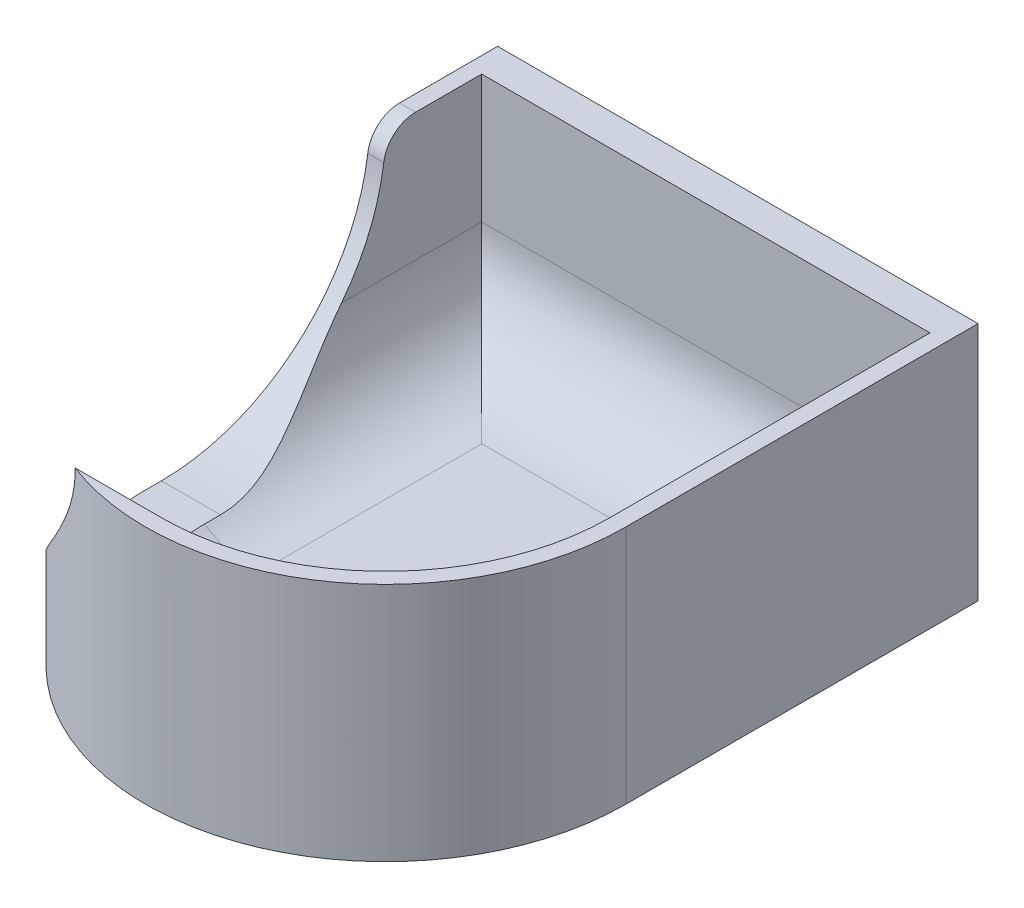
from build123d import *

# Parameters (mm, degrees)
BOSS_EXTRUDE1_DEPTH = 1.27
BOSS_EXTRUDE3_DEPTH = 17.78
SKETCH5_W           = 38.1
SKETCH5_H           = 19.05
BOSS_EXTRUDE4_DEPTH = 2.54
FILLET1_R           = 7.62
CUT_EXTRUDE5_REACH  = 40.1
FILLET3_R           = 2.54


with BuildPart() as part:
    # Sketch1 → Boss-Extrude1 (new body)
    with BuildSketch(Plane(origin=(0, 0, 0), x_dir=(1, 0, 0), z_dir=(0, 1, 0))):
        with BuildLine():
            Line((0, 0), (38.1, 0))
            Line((38.1, 0), (38.1, -25.4))
            ThreePointArc((38.1, -25.4), (19.05, -44.45), (0, -25.4))
            Line((0, -25.4), (0, 0))
        make_face()
    extrude(amount=BOSS_EXTRUDE1_DEPTH)

    # Sketch3 → Boss-Extrude3 (add)
    with BuildSketch(Plane(origin=(0, 1.27, 0), x_dir=(1, 0, 0), z_dir=(0, 1, 0))):
        with BuildLine():
            Line((0, 0), (0, -25.4))
            ThreePointArc((0, -25.4), (19.05, -44.45), (38.1, -25.4))
            Line((38.1, -25.4), (38.1, 0))
            Line((38.1, 0), (36.83, 0))
            Line((36.83, 0), (36.83, -25.4))
            ThreePointArc((36.83, -25.4), (19.05, -43.18), (1.27, -25.4))
            Line((1.27, -25.4), (1.27, 0))
            Line((1.27, 0), (0, 0))
        make_face()
    extrude(amount=BOSS_EXTRUDE3_DEPTH)

    # Sketch5 → Boss-Extrude4 (add)
    with BuildSketch(Plane(origin=(0, 0, 0), x_dir=(-1, 0, 0), z_dir=(0, 0, -1))):
        with Locations((-19.05, 9.525)):
            Rectangle(SKETCH5_W, SKETCH5_H)
    extrude(amount=BOSS_EXTRUDE4_DEPTH)

    # Fillet1
    fillet1_edges = [part.edges().sort_by_distance(p)[0] for p in [
        (19.05, 1.27, 0),
        (36.83, 1.27, 12.7),
        (19.05, 1.27, 43.18),
        (1.27, 1.27, 12.7),
    ]]
    fillet(fillet1_edges, radius=FILLET1_R)

    # Sketch9 → Cut-Extrude5 (cut, up to next)
    with BuildSketch(Plane.ZY, mode=Mode.PRIVATE) as cut_extrude5_sk1:
        with BuildLine():
            Line((24.13, 35.56), (26.67, 35.56))
            ThreePointArc((26.67, 35.56), (43.18, 19.05), (26.67, 2.54))
            Line((26.67, 2.54), (24.13, 2.54))
            ThreePointArc((24.13, 2.54), (7.62, 19.05), (24.13, 35.56))
        make_face()
    cut_extrude5_tool1 = extrude(cut_extrude5_sk1.sketch, amount=-CUT_EXTRUDE5_REACH, mode=Mode.PRIVATE) & part.part
    add(cut_extrude5_tool1.solids().sort_by_distance((0, 19.05, 25.4))[0], mode=Mode.SUBTRACT)

    # Fillet3
    fillet3_edges = [part.edges().sort_by_distance(p)[0] for p in [
        (0.635, 19.05, 7.62),
    ]]
    fillet(fillet3_edges, radius=FILLET3_R)


solid = part.part
